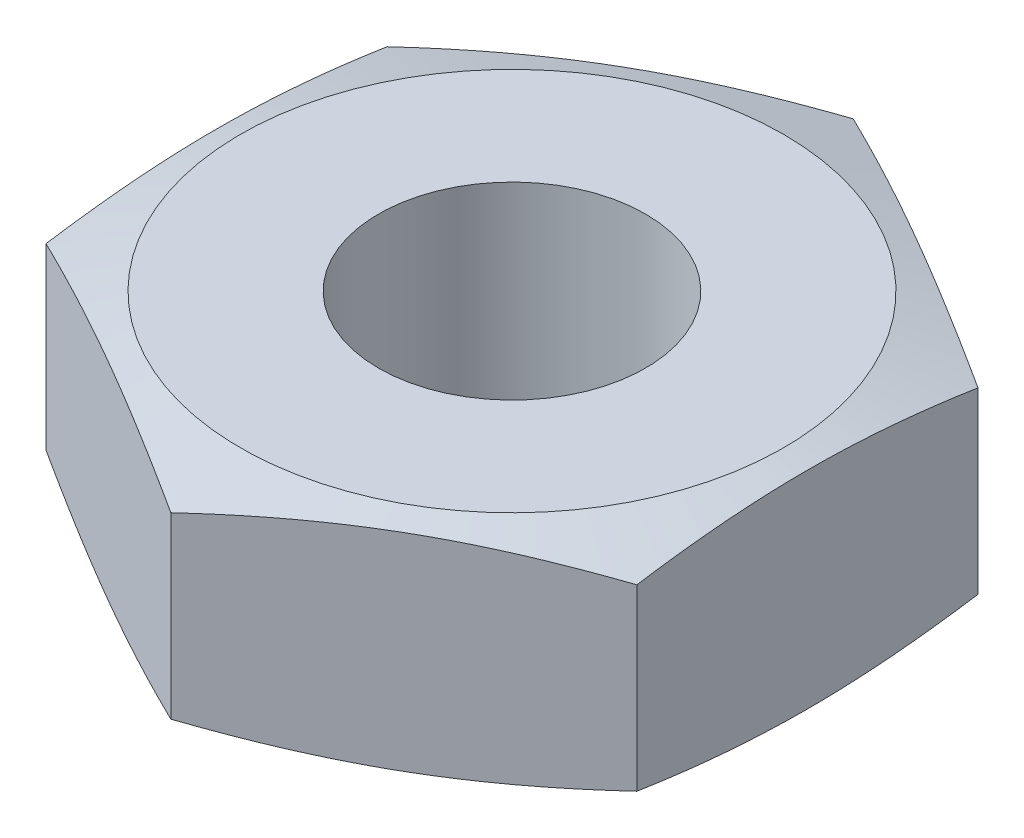
from build123d import *

# Parameters (mm, degrees)
SKETCH1_R           = 1.4351
BOSS_EXTRUDE1_DEPTH = 2.38125


with BuildPart() as part:
    # Sketch1 → Boss-Extrude1 (new body)
    with BuildSketch(Plane(origin=(0, 0, 0), x_dir=(1, 0, 0), z_dir=(0, 1, 0))):
        Polygon((0, -3.666174209), (3.175, -1.833087105), (3.175, 1.833087105), (0, 3.666174209), (-3.175, 1.833087105), (-3.175, -1.833087105), align=None)
        Circle(SKETCH1_R, mode=Mode.SUBTRACT)
    extrude(amount=BOSS_EXTRUDE1_DEPTH)

    # Sketch2 → Cut-Revolve1 (revolve, cut)
    with BuildSketch(Plane(origin=(0, 0, 0), x_dir=(0, 0, -1), z_dir=(1, 0, 0))):
        Polygon((2.918238424, 2.38125), (3.666174209, 2.151474904), (3.666174209, 2.38125), align=None)
        Polygon((2.918238424, 0), (3.666174209, 0), (3.666174209, 0.229775096), align=None)
    revolve(axis=Axis((0, 0, 0), (0, 1, 0)), mode=Mode.SUBTRACT)


solid = part.part
